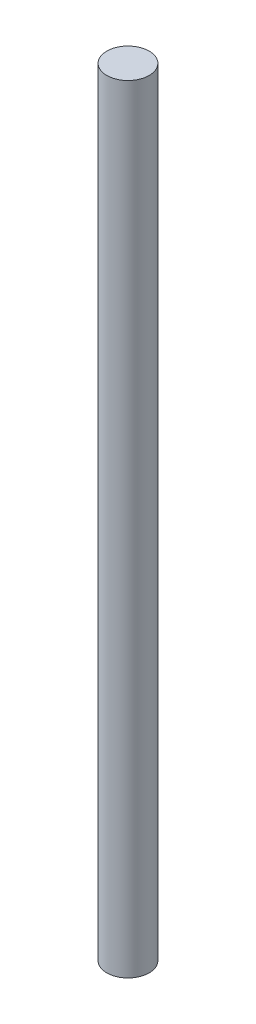
from build123d import *

# Parameters (mm, degrees)
ESBO_O1_R                = 9.525
RESSALTO_EXTRUS_O1_DEPTH = 350


with BuildPart() as part:
    # Esboço1 → Ressalto-extrusão1 (new body)
    with BuildSketch(Plane(origin=(0, 0, 0), x_dir=(1, 0, 0), z_dir=(0, 1, 0))):
        Circle(ESBO_O1_R)
    extrude(amount=RESSALTO_EXTRUS_O1_DEPTH)


solid = part.part
